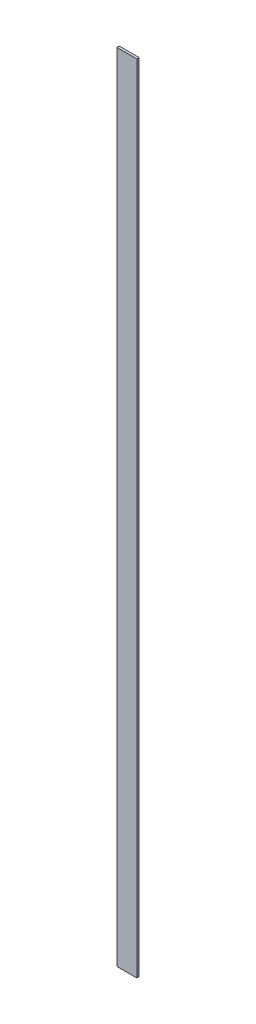
from build123d import *

# Parameters (mm, degrees)
SKETCH1_W           = 5
SKETCH1_H           = 200
BOSS_EXTRUDE1_DEPTH = 0.6


with BuildPart() as part:
    # Sketch1 → Boss-Extrude1 (new body)
    with BuildSketch(Plane.XY):
        Rectangle(SKETCH1_W, SKETCH1_H)
    extrude(amount=BOSS_EXTRUDE1_DEPTH)


solid = part.part
